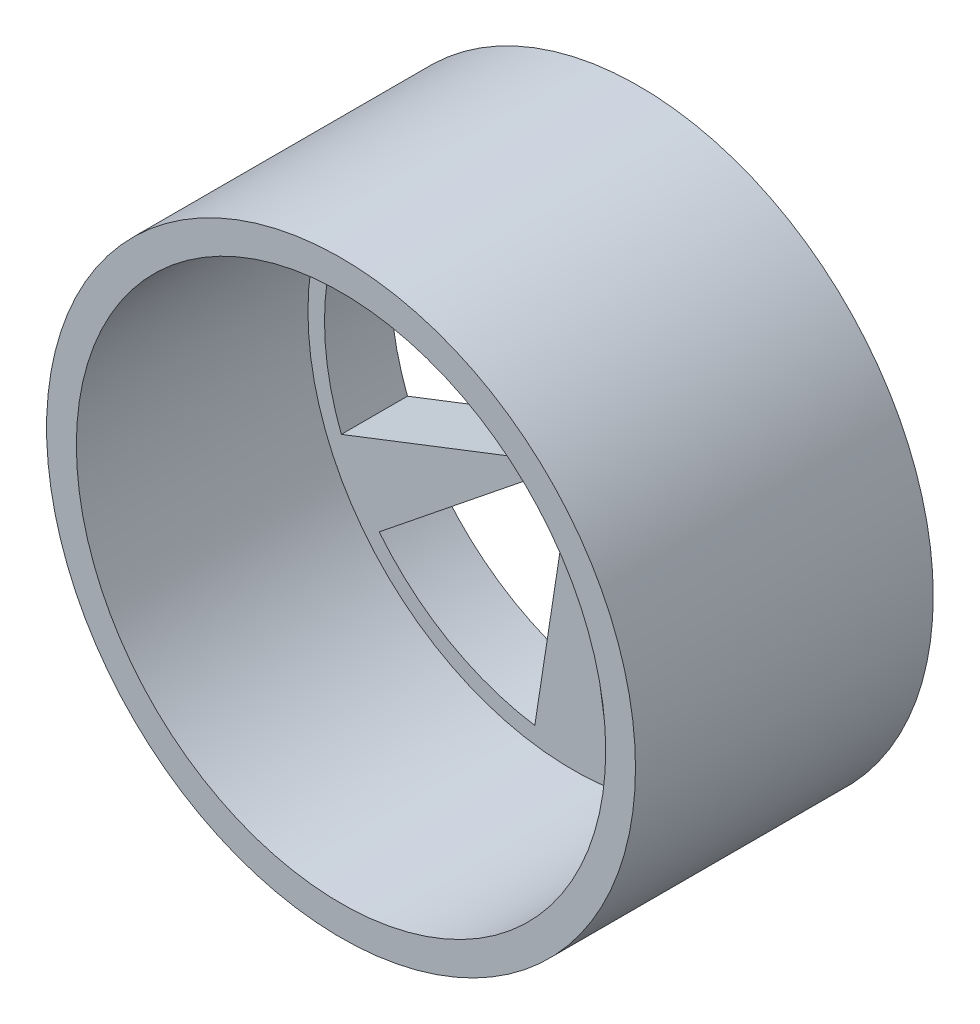
from build123d import *

# Parameters (mm, degrees)
SKETCH1_R           = 89
BOSS_EXTRUDE1_DEPTH = 90
CUT_EXTRUDE1_DEPTH  = 91
SKETCH3_R           = 80
CUT_EXTRUDE2_DEPTH  = 70
SKETCH4_R           = 10
CUT_EXTRUDE3_DEPTH  = 91


with BuildPart() as part:
    # Sketch1 → Boss-Extrude1 (new body)
    with BuildSketch(Plane.XY):
        with Locations((232.735026919, 15)):
            Circle(SKETCH1_R)
    extrude(amount=-BOSS_EXTRUDE1_DEPTH)

    # Sketch2 → Cut-Extrude1 (cut, through all)
    with BuildSketch(Plane.XY):
        with BuildLine():
            Line((221.301935747, 89.123440464), (230.448408684, 29.824688093))
            ThreePointArc((230.448408684, 29.824688093), (225.235026919, 27.990381057), (221.039779545, 24.392613526))
            Line((221.039779545, 24.392613526), (174.258790047, 61.963067631))
            ThreePointArc((174.258790047, 61.963067631), (195.235026919, 79.951905284), (221.301935747, 89.123440464))
        make_face()
        with BuildLine():
            Line((244.168118091, 89.123440464), (235.021645153, 29.824688093))
            ThreePointArc((235.021645153, 29.824688093), (240.235026919, 27.990381057), (244.430274293, 24.392613526))
            Line((244.430274293, 24.392613526), (291.211263791, 61.963067631))
            ThreePointArc((291.211263791, 61.963067631), (270.235026919, 79.951905284), (244.168118091, 89.123440464))
        make_face()
        with BuildLine():
            Line((162.825698875, 42.160372833), (218.75316131, 20.432074567))
            ThreePointArc((218.75316131, 20.432074567), (217.735026919, 15), (218.75316131, 9.567925433))
            Line((218.75316131, 9.567925433), (162.825698875, -12.160372833))
            ThreePointArc((162.825698875, -12.160372833), (157.735026919, 15), (162.825698875, 42.160372833))
        make_face()
        with BuildLine():
            Line((174.258790047, -31.963067631), (221.039779545, 5.607386474))
            ThreePointArc((221.039779545, 5.607386474), (225.235026919, 2.009618943), (230.448408684, 0.175311907))
            Line((230.448408684, 0.175311907), (221.301935747, -59.123440464))
            ThreePointArc((221.301935747, -59.123440464), (195.235026919, -49.951905284), (174.258790047, -31.963067631))
        make_face()
        with BuildLine():
            Line((244.168118091, -59.123440464), (235.021645153, 0.175311907))
            ThreePointArc((235.021645153, 0.175311907), (240.235026919, 2.009618943), (244.430274293, 5.607386474))
            Line((244.430274293, 5.607386474), (291.211263791, -31.963067631))
            ThreePointArc((291.211263791, -31.963067631), (270.235026919, -49.951905284), (244.168118091, -59.123440464))
        make_face()
        with BuildLine():
            Line((302.644354963, -12.160372833), (246.716892528, 9.567925433))
            ThreePointArc((246.716892528, 9.567925433), (247.735026919, 15), (246.716892528, 20.432074567))
            Line((246.716892528, 20.432074567), (302.644354963, 42.160372833))
            ThreePointArc((302.644354963, 42.160372833), (307.735026919, 15), (302.644354963, -12.160372833))
        make_face()
    extrude(amount=-CUT_EXTRUDE1_DEPTH, mode=Mode.SUBTRACT)

    # Sketch3 → Cut-Extrude2 (cut)
    with BuildSketch(Plane.XY):
        with Locations((232.735026919, 15)):
            Circle(SKETCH3_R)
    extrude(amount=-CUT_EXTRUDE2_DEPTH, mode=Mode.SUBTRACT)

    # Sketch4 → Cut-Extrude3 (cut, through all)
    with BuildSketch(Plane(origin=(0, 0, -90), x_dir=(-1, 0, 0), z_dir=(0, 0, -1))):
        with Locations((-232.735026919, 15)):
            Circle(SKETCH4_R)
    extrude(amount=-CUT_EXTRUDE3_DEPTH, mode=Mode.SUBTRACT)


solid = part.part
